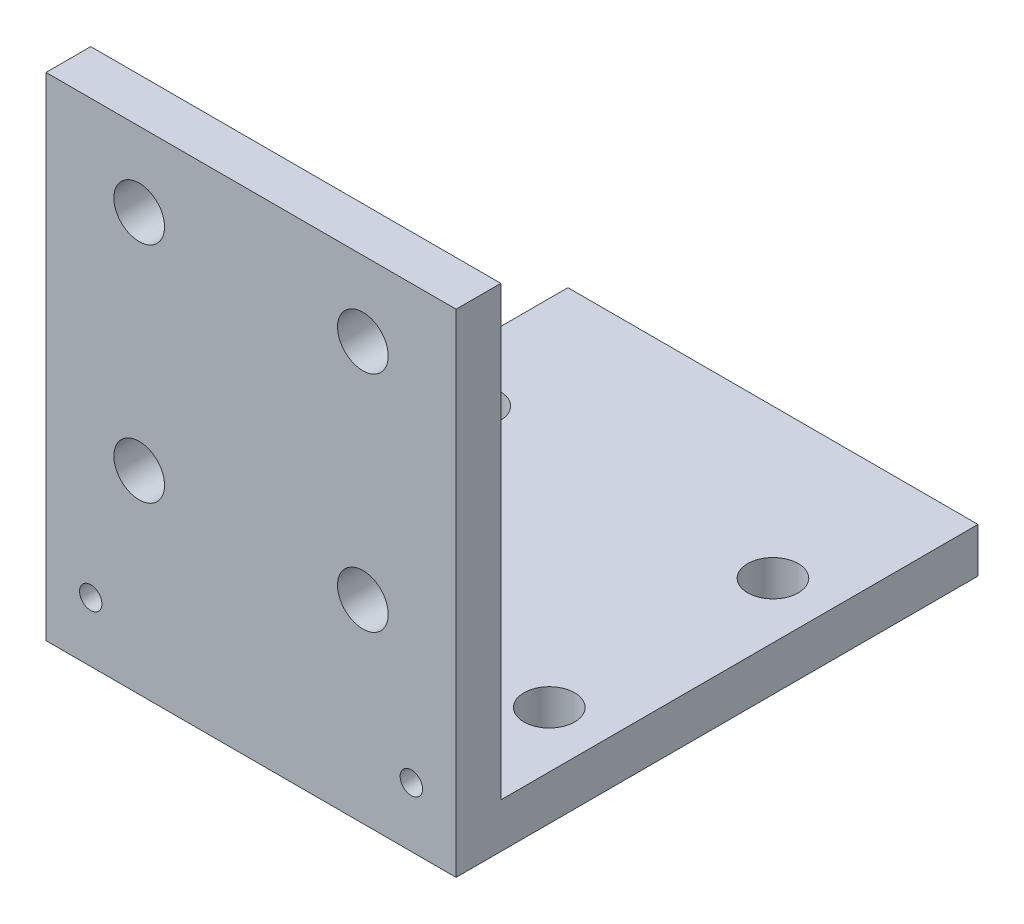
from build123d import *

# Parameters (mm, degrees)
SKETCH1_W                = 27.5
SKETCH1_H                = 3
BOSS_EXTRUDE1_DEPTH      = 35
SKETCH2_W                = 27.5
SKETCH2_H                = 3
BOSS_EXTRUDE2_DEPTH      = 40
M3_CLEARANCE_HOLE1_D     = 3.4
M3_CLEARANCE_HOLE1_DEPTH = 5
M3_CLEARANCE_HOLE1_TIP   = 1.021463052
SKETCH6_R                = 0.75
CUT_EXTRUDE1_DEPTH       = 10
M3_CLEARANCE_HOLE2_D     = 3.4
M3_CLEARANCE_HOLE2_DEPTH = 5
M3_CLEARANCE_HOLE2_TIP   = 1.021463052
SKETCH12_W               = 27.5
SKETCH12_H               = 10
CUT_EXTRUDE2_DEPTH       = 4


with BuildPart() as part:
    # Sketch1 → Boss-Extrude1 (new body)
    with BuildSketch(Plane.XY):
        Rectangle(SKETCH1_W, SKETCH1_H)
    extrude(amount=BOSS_EXTRUDE1_DEPTH)

    # Sketch2 → Boss-Extrude2 (add)
    with BuildSketch(Plane(origin=(0, 1.5, 0), x_dir=(1, 0, 0), z_dir=(0, 1, 0))):
        with Locations((0, -33.5)):
            Rectangle(SKETCH2_W, SKETCH2_H)
    extrude(amount=BOSS_EXTRUDE2_DEPTH)

    # M3 Clearance Hole1
    with Locations(Plane(origin=(0, 1.5, 0), x_dir=(1, 0, 0), z_dir=(0, 1, 0))):
        with Locations((-10, -10), (-10, -25), (10, -25), (10, -10)):
            Hole(M3_CLEARANCE_HOLE1_D / 2, depth=M3_CLEARANCE_HOLE1_DEPTH)
            with Locations((0, 0, -(M3_CLEARANCE_HOLE1_DEPTH + M3_CLEARANCE_HOLE1_TIP / 2))):  # 118° drill point
                Cone(0, M3_CLEARANCE_HOLE1_D / 2, M3_CLEARANCE_HOLE1_TIP, mode=Mode.SUBTRACT)

    # Sketch6 → Cut-Extrude1 (cut)
    with BuildSketch(Plane.XY.offset(35)):
        with Locations((-10.75, 2.5)):
            Circle(SKETCH6_R)
    cut_extrude1 = extrude(amount=-CUT_EXTRUDE1_DEPTH, mode=Mode.SUBTRACT)

    # M3 Clearance Hole2
    with Locations(Plane(origin=(0, 0, 32), x_dir=(-1, 0, 0), z_dir=(0, 0, -1))):
        with Locations((-7.5, 11.5), (7.5, 11.5), (7.5, 26.5), (-7.5, 26.5)):
            Hole(M3_CLEARANCE_HOLE2_D / 2, depth=M3_CLEARANCE_HOLE2_DEPTH)
            with Locations((0, 0, -(M3_CLEARANCE_HOLE2_DEPTH + M3_CLEARANCE_HOLE2_TIP / 2))):  # 118° drill point
                Cone(0, M3_CLEARANCE_HOLE2_D / 2, M3_CLEARANCE_HOLE2_TIP, mode=Mode.SUBTRACT)

    # Mirror1: Cut-Extrude1 across plane
    add(cut_extrude1.mirror(Plane(origin=(0, 0, 0), x_dir=(0, 0, 1), z_dir=(1, 0, 0))), mode=Mode.SUBTRACT)

    # Sketch12 → Cut-Extrude2 (cut, through all)
    with BuildSketch(Plane(origin=(0, 0, 32), x_dir=(-1, 0, 0), z_dir=(0, 0, -1))):
        with Locations((0, 36.5)):
            Rectangle(SKETCH12_W, SKETCH12_H)
    extrude(amount=-CUT_EXTRUDE2_DEPTH, mode=Mode.SUBTRACT)


solid = part.part
